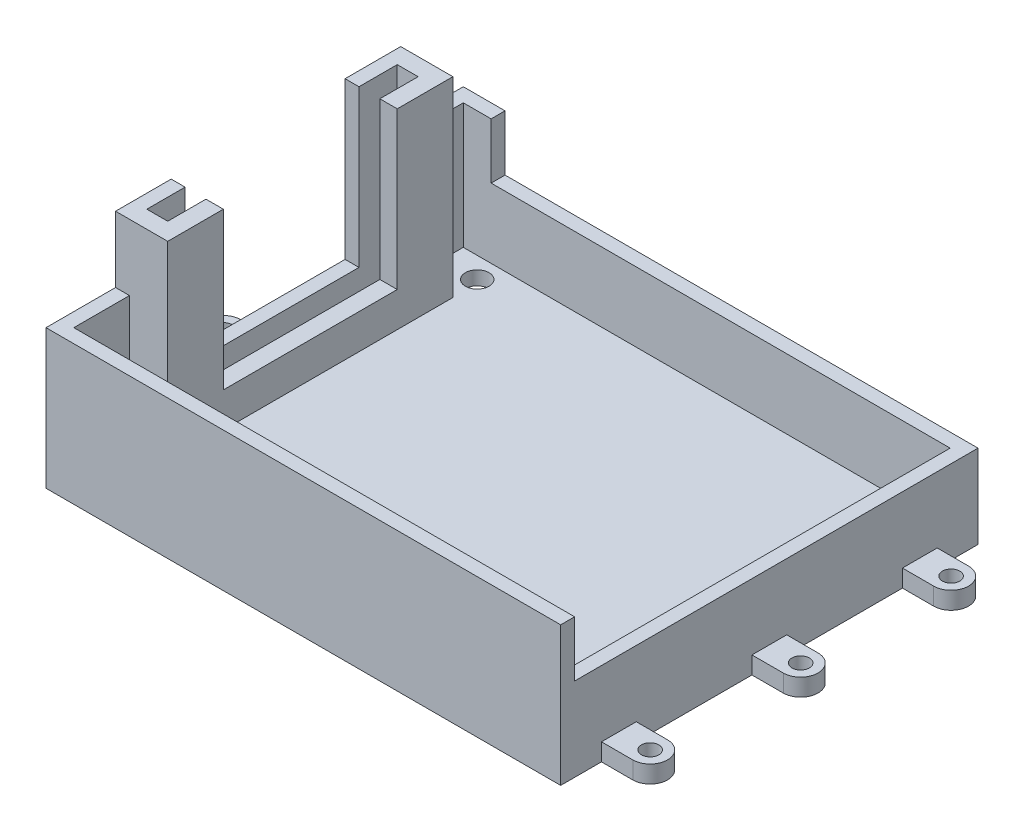
from build123d import *

# Parameters (mm, degrees)
SCHIZZO1_W                    = 74
SCHIZZO1_H                    = 60
ESTRUSIONE_ESTRUSIONE1_DEPTH  = 2
SCHIZZO2_W                    = 74
SCHIZZO2_H                    = 60
SCHIZZO2_W_2                  = 70
SCHIZZO2_H_2                  = 56
ESTRUSIONE_ESTRUSIONE2_DEPTH  = 18
SCHIZZO3_R                    = 1.7
TAGLIO_ESTRUSIONE1_DEPTH      = 8
SCHIZZO4_W                    = 68
SCHIZZO4_H                    = 8
TAGLIO_ESTRUSIONE2_DEPTH      = 56
TAGLIO_ESTRUSIONE2_DEPTH_BACK = 17
ESTRUSIONE_ESTRUSIONE3_DEPTH  = 27.5
SCHIZZO6_W                    = 2.5
SCHIZZO6_H                    = 25
ESTRUSIONE_ESTRUSIONE4_DEPTH  = 5
SCHIZZO7_W                    = 25
SCHIZZO7_H                    = 13
TAGLIO_ESTRUSIONE3_DEPTH      = 5
SCHIZZO8_W                    = 2
SCHIZZO8_H                    = 8
ESTRUSIONE_ESTRUSIONE5_DEPTH  = 9.5
SCHIZZO9_R                    = 1.25
ESTRUSIONE_ESTRUSIONE6_DEPTH  = 2.5


with BuildPart() as part:
    # Schizzo1 → Estrusione-Estrusione1 (new body)
    with BuildSketch(Plane(origin=(0, 0, 0), x_dir=(1, 0, 0), z_dir=(0, 1, 0))):
        Rectangle(SCHIZZO1_W, SCHIZZO1_H)
    extrude(amount=ESTRUSIONE_ESTRUSIONE1_DEPTH)

    # Schizzo2 → Estrusione-Estrusione2 (add)
    with BuildSketch(Plane(origin=(0, 2, 0), x_dir=(1, 0, 0), z_dir=(0, 1, 0))):
        Rectangle(SCHIZZO2_W, SCHIZZO2_H)
        Rectangle(SCHIZZO2_W_2, SCHIZZO2_H_2, mode=Mode.SUBTRACT)
    extrude(amount=ESTRUSIONE_ESTRUSIONE2_DEPTH)

    # Schizzo3 → Taglio-Estrusione1 (cut)
    with BuildSketch(Plane.XZ):
        with Locations((-30, 25)):
            Circle(SCHIZZO3_R)
        with Locations((30, 25)):
            Circle(SCHIZZO3_R)
        with Locations((30, -25)):
            Circle(SCHIZZO3_R)
        with Locations((-30, -25)):
            Circle(SCHIZZO3_R)
    extrude(amount=-TAGLIO_ESTRUSIONE1_DEPTH, mode=Mode.SUBTRACT)

    # Schizzo4 → Taglio-Estrusione2 (cut, two sides)
    with BuildSketch(Plane.XY.offset(-28)) as taglio_estrusione2_sk:
        with Locations((3, 16)):
            Rectangle(SCHIZZO4_W, SCHIZZO4_H)
    extrude(amount=TAGLIO_ESTRUSIONE2_DEPTH, mode=Mode.SUBTRACT)
    extrude(taglio_estrusione2_sk.sketch, amount=-TAGLIO_ESTRUSIONE2_DEPTH_BACK, mode=Mode.SUBTRACT)

    # Schizzo5 → Estrusione-Estrusione3 (add)
    with BuildSketch(Plane(origin=(0, 2, 0), x_dir=(1, 0, 0), z_dir=(0, 1, 0))):
        Polygon((-35, 21), (-29.5, 21), (-29.5, 15.569709151), (-29.5, 13), (-32, 13), (-32, 18.5), (-35, 18.5), align=None)
        Polygon((-29.5, -12), (-29.5, -6.768227203), (-29.5, -20), (-35, -20), (-35, -17.5), (-32, -17.5), (-32, -12), align=None)
    extrude(amount=ESTRUSIONE_ESTRUSIONE3_DEPTH)

    # Schizzo6 → Estrusione-Estrusione4 (add)
    with BuildSketch(Plane(origin=(0, 2, 0), x_dir=(1, 0, 0), z_dir=(0, 1, 0))):
        with Locations((-30.75, 0.5)):
            Rectangle(SCHIZZO6_W, SCHIZZO6_H)
    extrude(amount=ESTRUSIONE_ESTRUSIONE4_DEPTH)

    # Schizzo7 → Taglio-Estrusione3 (cut)
    with BuildSketch(Plane(origin=(-35, 0, 0), x_dir=(0, 0, -1), z_dir=(1, 0, 0))):
        with Locations((0.5, 13.5)):
            Rectangle(SCHIZZO7_W, SCHIZZO7_H)
    extrude(amount=-TAGLIO_ESTRUSIONE3_DEPTH, mode=Mode.SUBTRACT)

    # Schizzo8 → Estrusione-Estrusione5 (add)
    with BuildSketch(Plane(origin=(0, 20, 0), x_dir=(1, 0, 0), z_dir=(0, 1, 0))):
        with Locations((-36, 17)):
            Rectangle(SCHIZZO8_W, SCHIZZO8_H)
        with Locations((-36, -16)):
            Rectangle(SCHIZZO8_W, SCHIZZO8_H)
    extrude(amount=ESTRUSIONE_ESTRUSIONE5_DEPTH)

    # Schizzo9 → Estrusione-Estrusione6 (add)
    with BuildSketch(Plane.XZ):
        with BuildLine():
            Line((-37, -24.136555447), (-37, -19.136555447))
            Line((-37, -19.136555447), (-41.5, -19.136555447))
            ThreePointArc((-41.5, -19.136555447), (-44, -21.636555447), (-41.5, -24.136555447))
            Line((-41.5, -24.136555447), (-37, -24.136555447))
        make_face()
        with Locations((-41.5, -21.636555447)):
            Circle(SCHIZZO9_R, mode=Mode.SUBTRACT)
        with BuildLine():
            Line((-37, -2.5), (-37, 2.5))
            Line((-37, 2.5), (-41.5, 2.5))
            ThreePointArc((-41.5, 2.5), (-44, 0), (-41.5, -2.5))
            Line((-41.5, -2.5), (-37, -2.5))
        make_face()
        with Locations((-41.5, 0)):
            Circle(SCHIZZO9_R, mode=Mode.SUBTRACT)
        with BuildLine():
            Line((-37, 19.136555447), (-37, 24.136555447))
            Line((-37, 24.136555447), (-41.5, 24.136555447))
            ThreePointArc((-41.5, 24.136555447), (-44, 21.636555447), (-41.5, 19.136555447))
            Line((-41.5, 19.136555447), (-37, 19.136555447))
        make_face()
        with Locations((-41.5, 21.636555447)):
            Circle(SCHIZZO9_R, mode=Mode.SUBTRACT)
        with BuildLine():
            Line((37, 24.136555447), (37, 19.136555447))
            Line((37, 19.136555447), (41.5, 19.136555447))
            ThreePointArc((41.5, 19.136555447), (44, 21.636555447), (41.5, 24.136555447))
            Line((41.5, 24.136555447), (37, 24.136555447))
        make_face()
        with Locations((41.5, 21.636555447)):
            Circle(SCHIZZO9_R, mode=Mode.SUBTRACT)
        with BuildLine():
            Line((37, 2.5), (37, -2.5))
            Line((37, -2.5), (41.5, -2.5))
            ThreePointArc((41.5, -2.5), (44, 0), (41.5, 2.5))
            Line((41.5, 2.5), (37, 2.5))
        make_face()
        with Locations((41.5, 0)):
            Circle(SCHIZZO9_R, mode=Mode.SUBTRACT)
        with BuildLine():
            Line((37, -19.136555447), (37, -24.136555447))
            Line((37, -24.136555447), (41.5, -24.136555447))
            ThreePointArc((41.5, -24.136555447), (44, -21.636555447), (41.5, -19.136555447))
            Line((41.5, -19.136555447), (37, -19.136555447))
        make_face()
        with Locations((41.5, -21.636555447)):
            Circle(SCHIZZO9_R, mode=Mode.SUBTRACT)
    extrude(amount=-ESTRUSIONE_ESTRUSIONE6_DEPTH)


solid = part.part
